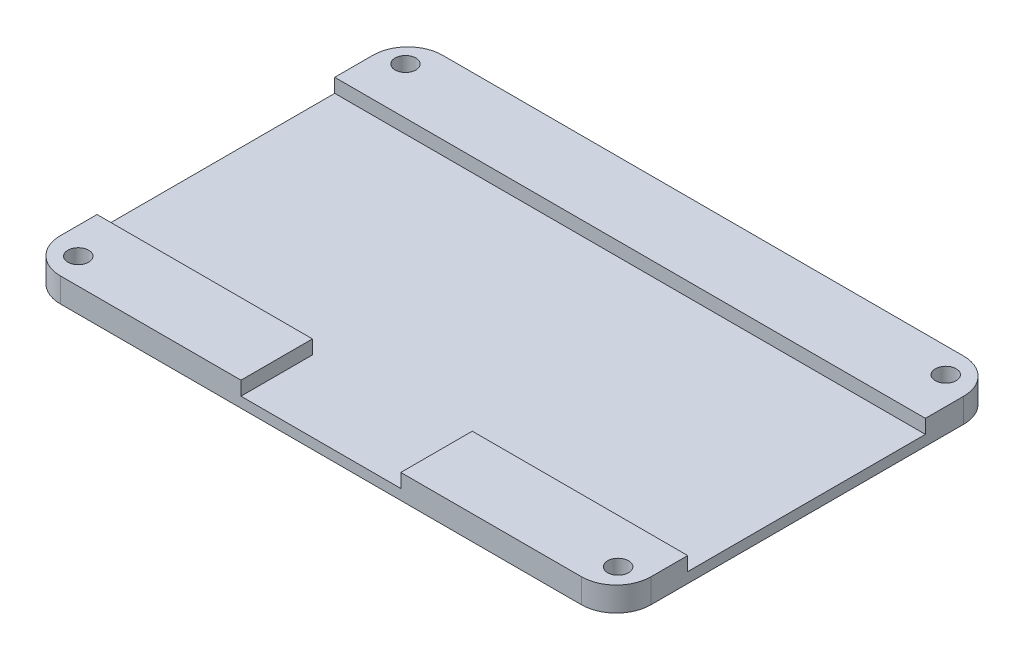
from build123d import *

# Parameters (mm, degrees)
BOSS_EXTRUDE1_DEPTH = 3.5
SKETCH2_R           = 1.5
CUT_EXTRUDE1_DEPTH  = 3.5
SKETCH3_W           = 23
SKETCH3_H           = 10.283770076
CUT_EXTRUDE2_DEPTH  = 2


with BuildPart() as part:
    # Sketch1 → Boss-Extrude1 (new body)
    with BuildSketch(Plane(origin=(0, 0, 0), x_dir=(1, 0, 0), z_dir=(0, 1, 0))):
        with BuildLine():
            Line((-20.62248996, 7.565261044), (54.37751004, 7.565261044))
            ThreePointArc((54.37751004, 7.565261044), (57.913043946, 6.10079495), (59.37751004, 2.565261044))
            Line((59.37751004, 2.565261044), (59.37751004, -42.434738956))
            ThreePointArc((59.37751004, -42.434738956), (57.913043946, -45.970272862), (54.37751004, -47.434738956))
            Line((54.37751004, -47.434738956), (-20.62248996, -47.434738956))
            ThreePointArc((-20.62248996, -47.434738956), (-24.158023866, -45.970272862), (-25.62248996, -42.434738956))
            Line((-25.62248996, -42.434738956), (-25.62248996, 2.565261044))
            ThreePointArc((-25.62248996, 2.565261044), (-24.158023866, 6.10079495), (-20.62248996, 7.565261044))
        make_face()
    extrude(amount=BOSS_EXTRUDE1_DEPTH)

    # Sketch2 → Cut-Extrude1 (cut)
    with BuildSketch(Plane(origin=(0, 3.5, 0), x_dir=(1, 0, 0), z_dir=(0, 1, 0))):
        with Locations((-22.187566987, 3.802718615)):
            Circle(SKETCH2_R)
        with Locations((55.412433013, 3.947865339)):
            Circle(SKETCH2_R)
        with Locations((55.766505812, -43.552134661)):
            Circle(SKETCH2_R)
        with Locations((-21.775437199, -43.697281385)):
            Circle(SKETCH2_R)
    extrude(amount=-CUT_EXTRUDE1_DEPTH, mode=Mode.SUBTRACT)

    # Sketch3 → Cut-Extrude2 (cut)
    with BuildSketch(Plane(origin=(0, 3.5, 0), x_dir=(1, 0, 0), z_dir=(0, 1, 0))):
        with Locations((16.87751004, -42.292853918)):
            Rectangle(SKETCH3_W, SKETCH3_H)
        Polygon((59.37751004, -2.947281385), (-25.62248996, -2.947281385), (-25.62248996, -37.15096888), (5.37751004, -37.15096888), (28.37751004, -37.15096888), (59.37751004, -37.15096888), align=None)
    extrude(amount=-CUT_EXTRUDE2_DEPTH, mode=Mode.SUBTRACT)


solid = part.part
